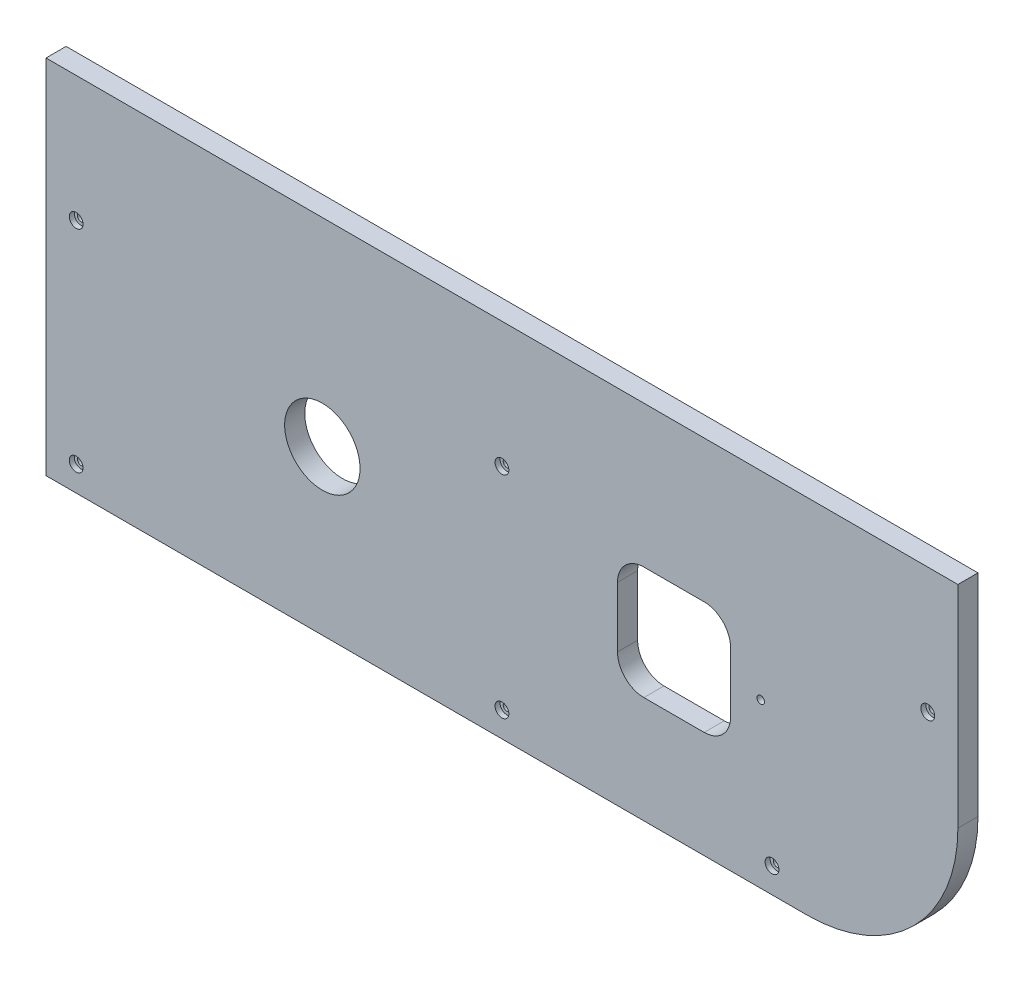
from build123d import *

# Parameters (mm, degrees)
BOSS_EXTRU_1_DEPTH                                 = 8
ESQUISSE2_R                                        = 15
ESQUISSE2_R_2                                      = 1.5
ENL_V_MAT_EXTRU_1_DEPTH                            = 9
CHAMBRAGE_POUR_VIS_T_TE_CYLINDRIQUE_CO_D           = 3
CHAMBRAGE_POUR_VIS_T_TE_CYLINDRIQUE_CO_CBORE_D     = 5.5
CHAMBRAGE_POUR_VIS_T_TE_CYLINDRIQUE_CO_CBORE_DEPTH = 2


with BuildPart() as part:
    # Esquisse1 → Boss.-Extru.1 (new body)
    with BuildSketch(Plane.XY):
        with BuildLine():
            Line((-162, -49), (201, -49))
            Line((201, -49), (201, -133))
            ThreePointArc((201, -133), (183.426406871, -175.426406871), (141, -193))
            Line((141, -193), (-162, -193))
            Line((-162, -193), (-162, -49))
        make_face()
    extrude(amount=BOSS_EXTRU_1_DEPTH)

    # Esquisse2 → Enlèv. mat.-Extru.1 (cut, through all)
    with BuildSketch(Plane.XY.offset(8)):
        with Locations((-52, -128)):
            Circle(ESQUISSE2_R)
        with Locations((122.5, -128)):
            Circle(ESQUISSE2_R_2)
        with BuildLine():
            Line((76, -150.5), (100, -150.5))
            ThreePointArc((100, -150.5), (107.424621202, -147.424621202), (110.5, -140))
            Line((110.5, -140), (110.5, -116))
            ThreePointArc((110.5, -116), (107.424621202, -108.575378798), (100, -105.5))
            Line((100, -105.5), (76, -105.5))
            ThreePointArc((76, -105.5), (68.575378798, -108.575378798), (65.5, -116))
            Line((65.5, -116), (65.5, -140))
            ThreePointArc((65.5, -140), (68.575378798, -147.424621202), (76, -150.5))
        make_face()
    extrude(amount=-ENL_V_MAT_EXTRU_1_DEPTH, mode=Mode.SUBTRACT)

    # Chambrage pour vis à tête cylindrique courte six pans creux M31 (through all)
    with Locations(Plane.XY.offset(8)):
        with Locations((-150, -99), (19.5, -99), (189, -99), (-150, -183), (19.5, -183), (127, -183)):
            CounterBoreHole(CHAMBRAGE_POUR_VIS_T_TE_CYLINDRIQUE_CO_D / 2, CHAMBRAGE_POUR_VIS_T_TE_CYLINDRIQUE_CO_CBORE_D / 2, CHAMBRAGE_POUR_VIS_T_TE_CYLINDRIQUE_CO_CBORE_DEPTH)


solid = part.part
